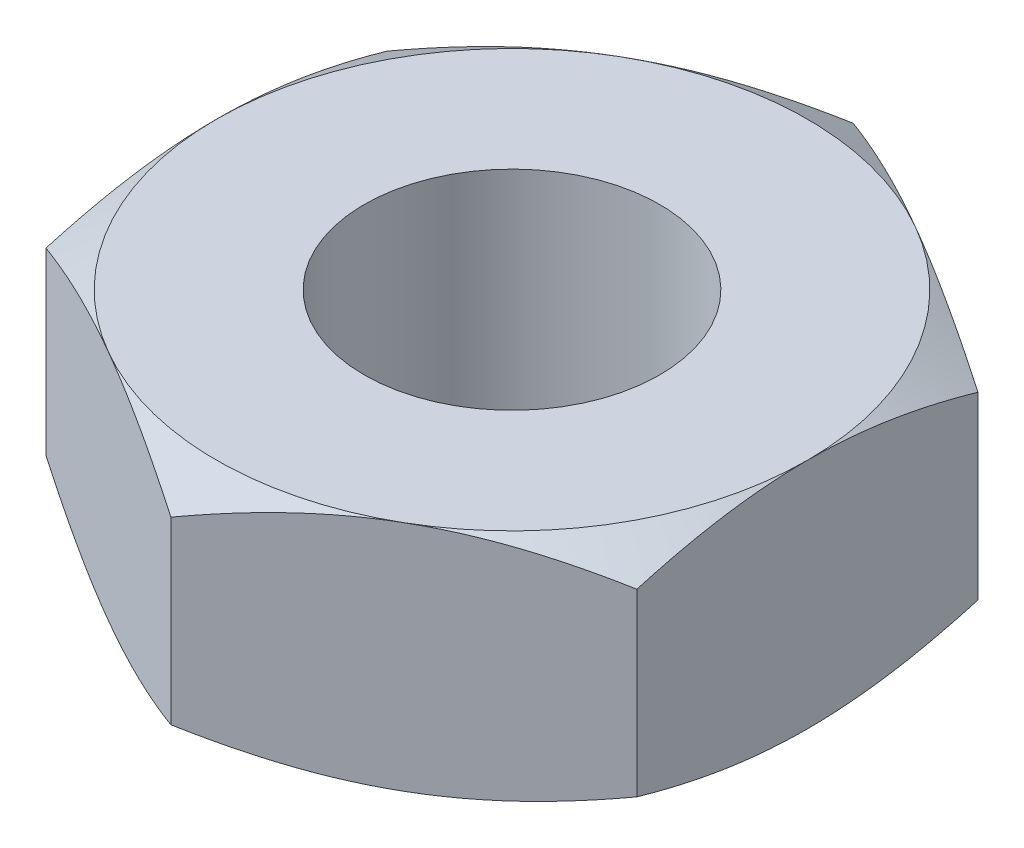
from build123d import *

# Parameters (mm, degrees)
BOSS_EXTRUDE1_DEPTH = 5
SKETCH2_R           = 6.35
CUT_EXTRUDE1_DEPTH  = 11
SKETCH3_OUTSIDE_W   = 73.518
SKETCH3_OUTSIDE_H   = 77.448
SKETCH3_OUTSIDE_R   = 12.7
CUT_EXTRUDE2_DEPTH  = 11
CUT_EXTRUDE2_TAPER  = 60


with BuildPart() as part:
    # Sketch1 → Boss-Extrude1 (new body, symmetric)
    with BuildSketch(Plane(origin=(0, 0, 0), x_dir=(1, 0, 0), z_dir=(0, 1, 0))):
        Polygon((-12.7, -7.332348419), (0, -14.664696837), (12.7, -7.332348419), (12.7, 7.332348419), (0, 14.664696837), (-12.7, 7.332348419), align=None)
    extrude(amount=BOSS_EXTRUDE1_DEPTH, both=True)

    # Sketch2 → Cut-Extrude1 (cut, through all)
    with BuildSketch(Plane(origin=(0, 5, 0), x_dir=(1, 0, 0), z_dir=(0, 1, 0))):
        Circle(SKETCH2_R)
    extrude(amount=-CUT_EXTRUDE1_DEPTH, mode=Mode.SUBTRACT)

    # Sketch3 outside → Cut-Extrude2 (cut, through all)
    with BuildSketch(Plane(origin=(0, 5, 0), x_dir=(1, 0, 0), z_dir=(0, 1, 0))):
        Rectangle(SKETCH3_OUTSIDE_W, SKETCH3_OUTSIDE_H)
        Circle(SKETCH3_OUTSIDE_R, mode=Mode.SUBTRACT)
    cut_extrude2 = extrude(amount=-CUT_EXTRUDE2_DEPTH, taper=CUT_EXTRUDE2_TAPER, mode=Mode.SUBTRACT)

    # Mirror1: Cut-Extrude2 across plane
    add(cut_extrude2.mirror(Plane.ZX), mode=Mode.SUBTRACT)


solid = part.part
